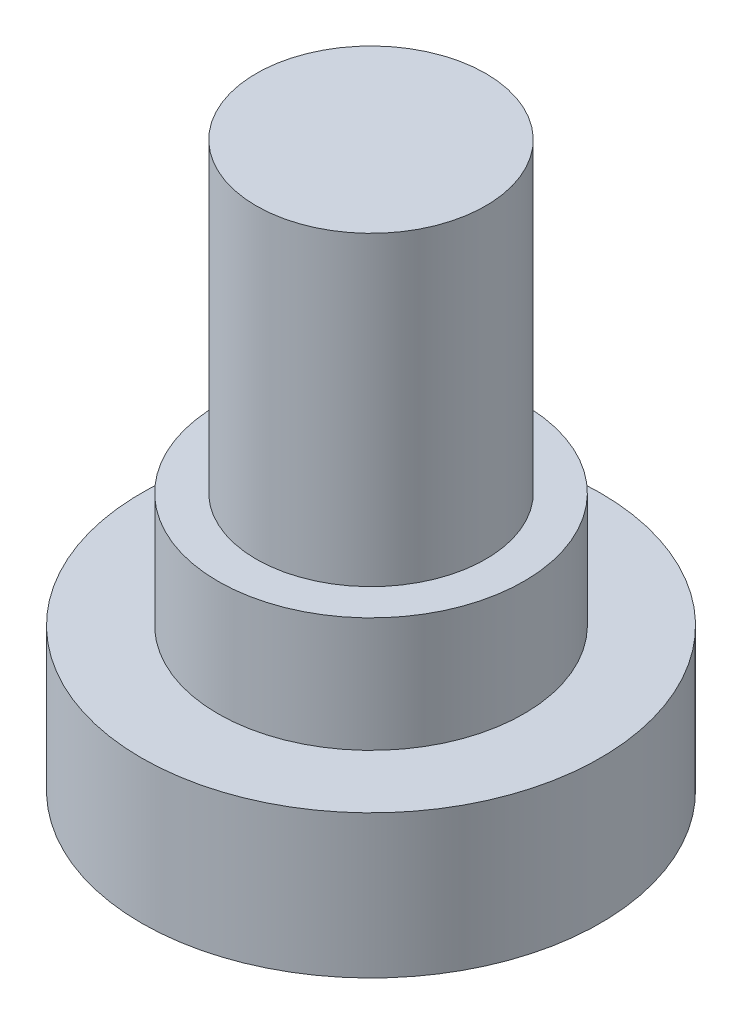
from build123d import *

# Parameters (mm, degrees)
SKETCH_1_R      = 6
EXTRUDE_1_DEPTH = 3.74
SKETCH_2_R      = 4
EXTRUDE_2_DEPTH = 3
SKETCH_3_R      = 3
EXTRUDE_3_DEPTH = 8


with BuildPart() as part:
    # 草图1 → 凸台-拉伸1 (new body)
    with BuildSketch(Plane(origin=(0, 0, 0), x_dir=(1, 0, 0), z_dir=(0, 1, 0))):
        Circle(SKETCH_1_R)
    extrude(amount=EXTRUDE_1_DEPTH)

    # 草图2 → 凸台-拉伸2 (add)
    with BuildSketch(Plane(origin=(0, 3.74, 0), x_dir=(1, 0, 0), z_dir=(0, 1, 0))):
        Circle(SKETCH_2_R)
    extrude(amount=EXTRUDE_2_DEPTH)

    # 草图3 → 凸台-拉伸3 (add)
    with BuildSketch(Plane(origin=(0, 6.74, 0), x_dir=(1, 0, 0), z_dir=(0, 1, 0))):
        Circle(SKETCH_3_R)
    extrude(amount=EXTRUDE_3_DEPTH)


solid = part.part
